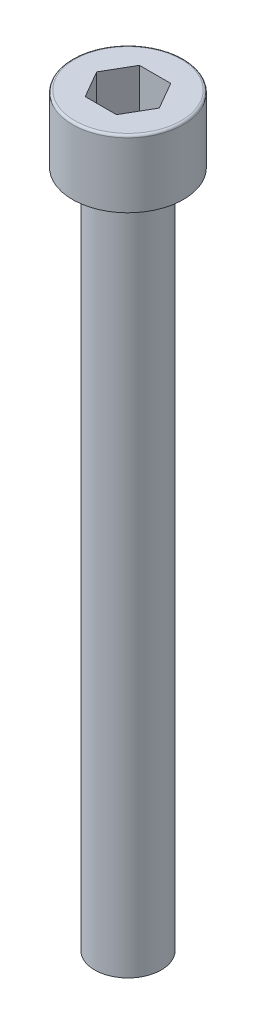
from build123d import *

# Parameters (mm, degrees)
CORTAR_EXTRUIR1_DEPTH = 3.9
REDONDEO1_R           = 0.2


with BuildPart() as part:
    # Croquis1 → Revolución1 (revolve)
    with BuildSketch(Plane.XY):
        Polygon((0, 37.735435589), (0, -28.264564411), (-2, -28.264564411), (-2.925, -27.764564411), (-2.925, 31.835435589), (-4.875, 31.835435589), (-4.875, 37.735435589), align=None)
    revolve(axis=Axis((0, 37.735435589, 0), (0, -1, 0)))

    # Croquis2 → Cortar-Extruir1 (cut)
    with BuildSketch(Plane(origin=(0, 37.735435589, 0), x_dir=(1, 0, 0), z_dir=(0, 1, 0))):
        Polygon((2.75, 0), (1.375, 2.38156986), (-1.375, 2.38156986), (-2.75, 0), (-1.375, -2.38156986), (1.375, -2.38156986), align=None)
    extrude(amount=-CORTAR_EXTRUIR1_DEPTH, mode=Mode.SUBTRACT)

    # Redondeo1
    redondeo1_edges = [part.edges().sort_by_distance(p)[0] for p in [
        (4.875, 37.735435589, 0),
    ]]
    fillet(redondeo1_edges, radius=REDONDEO1_R)


solid = part.part
